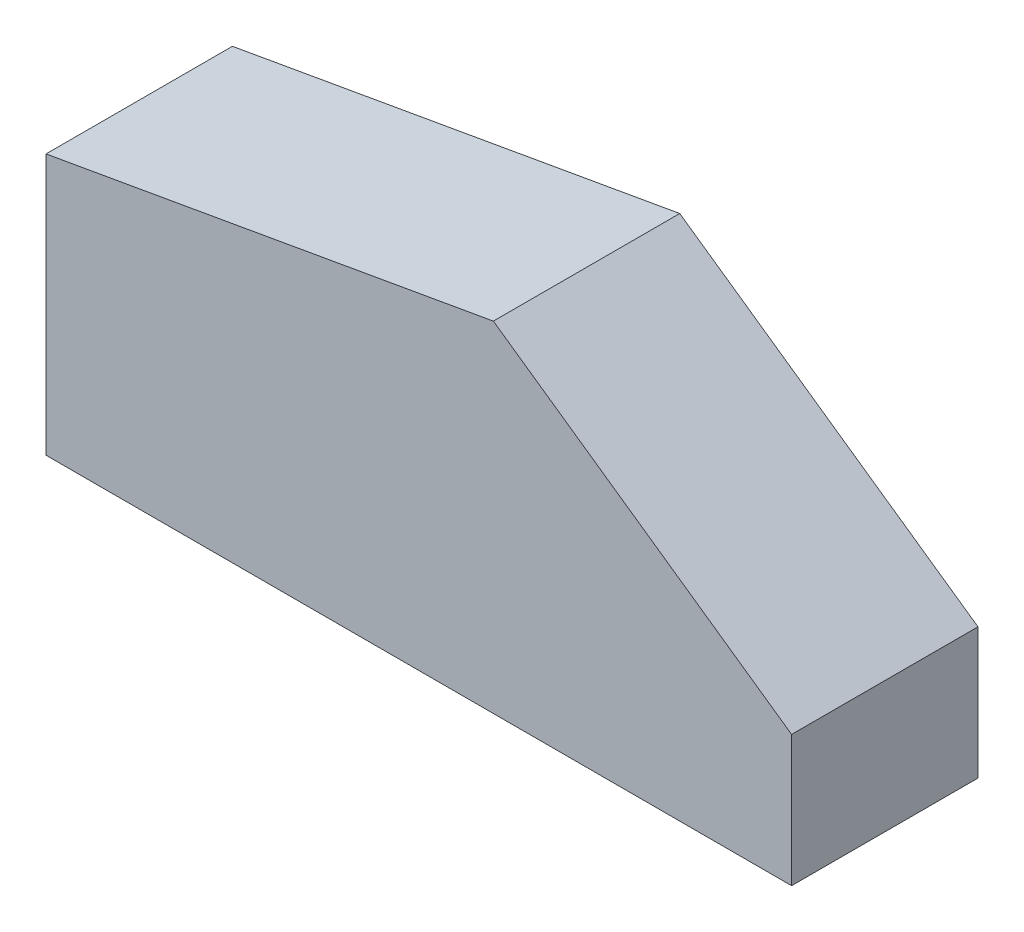
from build123d import *

# Parameters (mm, degrees)
BOSS_EXTRUDE1_DEPTH = 25


with BuildPart() as part:
    # Sketch1 → Boss-Extrude1 (new body)
    with BuildSketch(Plane.XY):
        Polygon((0, 0), (0, 35), (60, 45.579618843), (100, 17.571317314), (100, 0), align=None)
    extrude(amount=BOSS_EXTRUDE1_DEPTH)


solid = part.part
